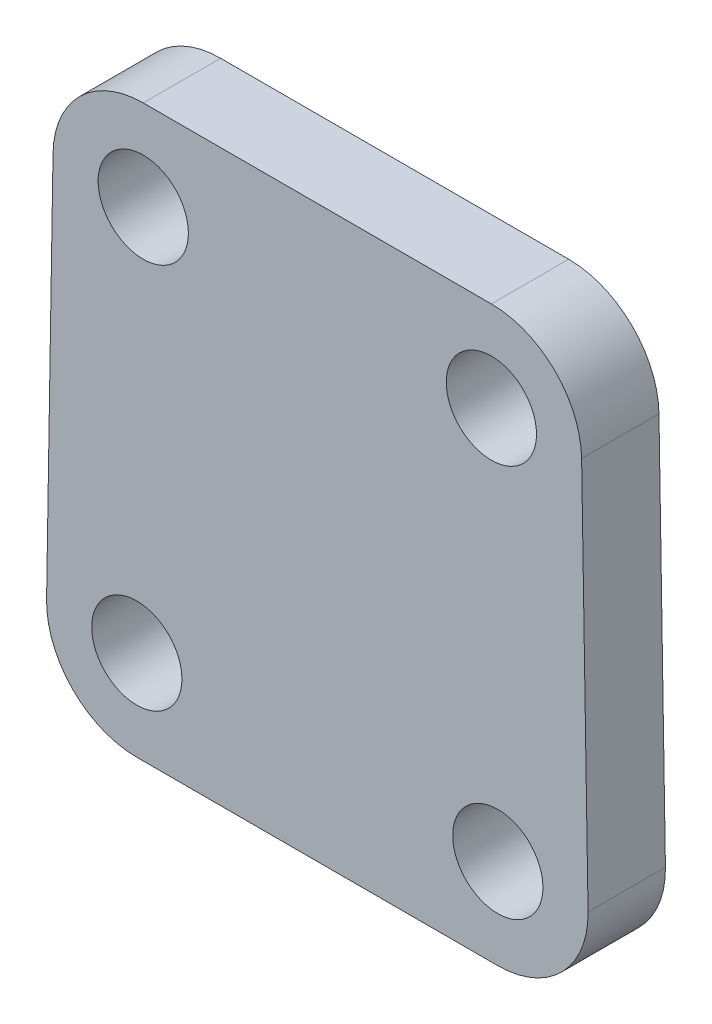
from build123d import *

# Parameters (mm, degrees)
ESQUISSE1_R        = 1.75
BOSS_EXTRU_1_DEPTH = 3
CONG_1_R           = 3.5


with BuildPart() as part:
    # Esquisse1 → Boss.-Extru.1 (new body)
    with BuildSketch(Plane.XY):
        Polygon((-10.55794702, -7.3), (-10.19205298, 14.8), (10.19205298, 14.8), (10.55794702, -7.3), align=None)
        with Locations((-6.75, 11.3)):
            Circle(ESQUISSE1_R, mode=Mode.SUBTRACT)
        with Locations((6.75, 11.3)):
            Circle(ESQUISSE1_R, mode=Mode.SUBTRACT)
        with Locations((-7, -3.8)):
            Circle(ESQUISSE1_R, mode=Mode.SUBTRACT)
        with Locations((7, -3.8)):
            Circle(ESQUISSE1_R, mode=Mode.SUBTRACT)
    extrude(amount=BOSS_EXTRU_1_DEPTH)

    # Congé1
    cong_1_edges = [part.edges().sort_by_distance(p)[0] for p in [
        (-10.55794702, -7.3, 1.5),
        (-10.19205298, 14.8, 1.5),
        (10.19205298, 14.8, 1.5),
        (10.55794702, -7.3, 1.5),
    ]]
    fillet(cong_1_edges, radius=CONG_1_R)


solid = part.part
